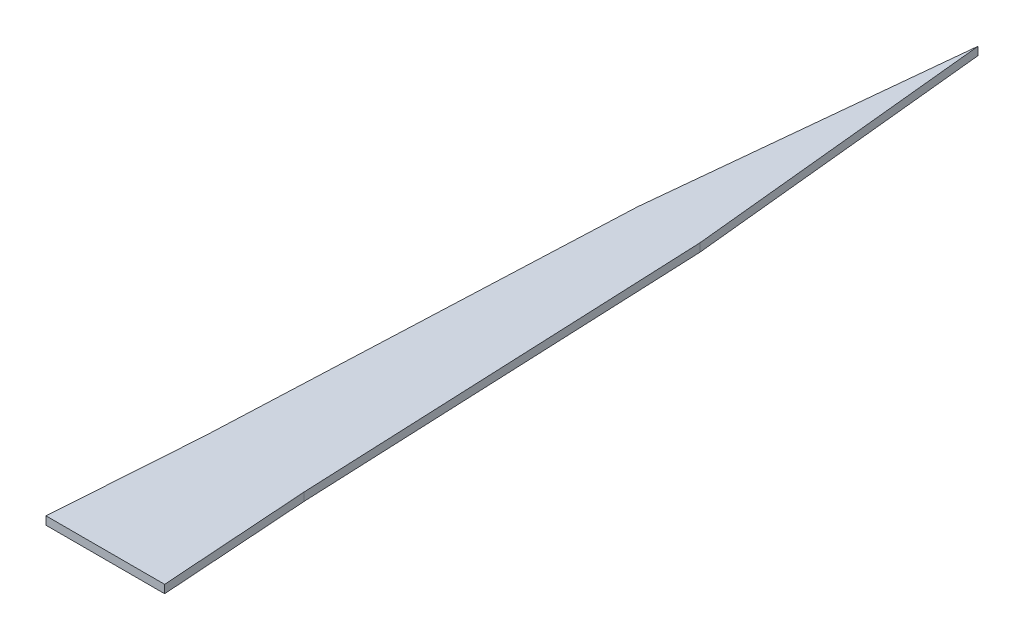
from build123d import *

# Parameters (mm, degrees)
BOSS_EXTRU_1_DEPTH = 2


with BuildPart() as part:
    # Esquisse1 → Boss.-Extru.1 (new body)
    with BuildSketch(Plane(origin=(0, 0, 0), x_dir=(1, 0, 0), z_dir=(0, 1, 0))):
        Polygon((22.162174421, 137.965870962), (14.525454482, 213.65805103), (6.888734543, 137.965870962), (2.506935547, 36.577685564), (0, 0), (29.050908964, 0), (26.543973417, 36.577685564), align=None)
    extrude(amount=BOSS_EXTRU_1_DEPTH)


solid = part.part
